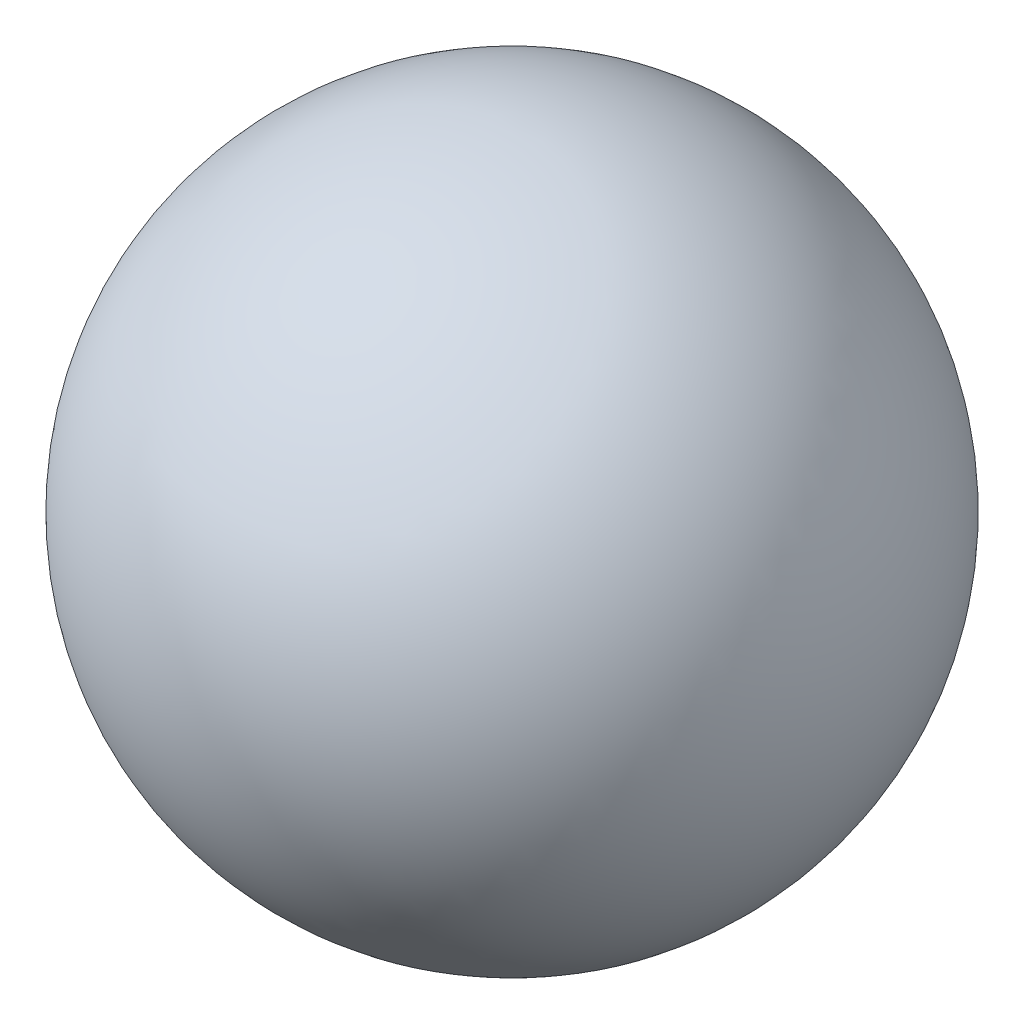
from build123d import *


with BuildPart() as part:
    # Sketch1 → Revolve1 (revolve)
    with BuildSketch(Plane.XY):
        with BuildLine():
            Line((0, 3.95), (0, -3.95))
            ThreePointArc((0, -3.95), (3.95, 0), (0, 3.95))
        make_face()
    revolve(axis=Axis((0, 3.95, 0), (0, -1, 0)))


solid = part.part
